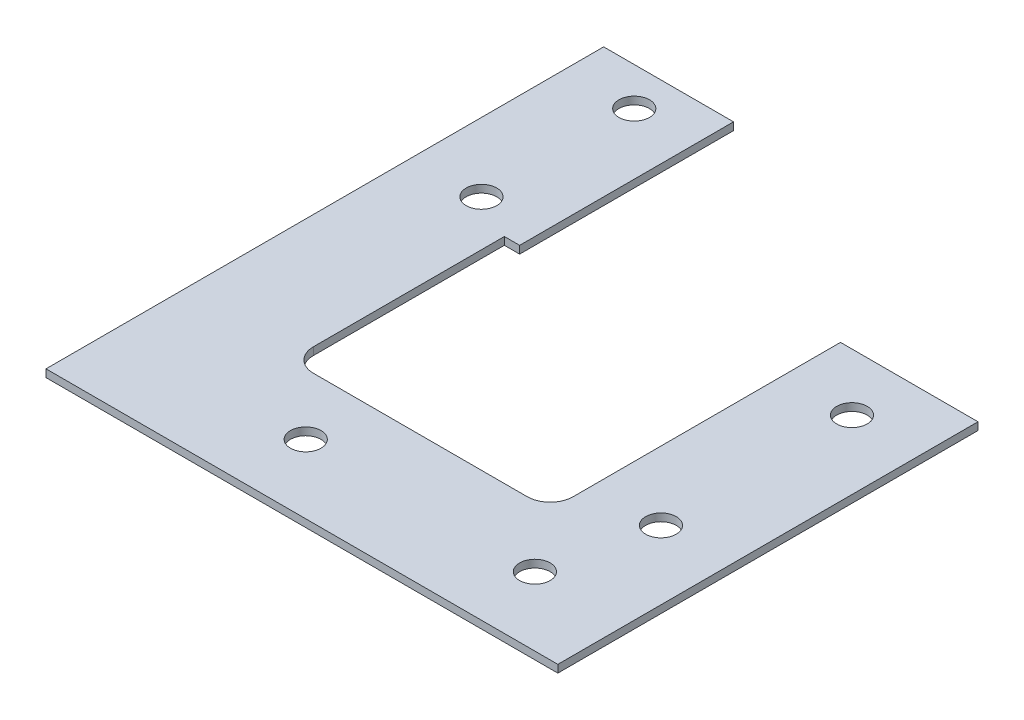
from build123d import *

# Parameters (mm, degrees)
SKETCH1_R           = 2
BOSS_EXTRUDE2_DEPTH = 1


with BuildPart() as part:
    # Sketch1 → Boss-Extrude2 (new body)
    with BuildSketch(Plane(origin=(0, 0, 0), x_dir=(1, 0, 0), z_dir=(0, 1, 0))):
        with BuildLine():
            Line((0, 40), (15, 40))
            Line((15, 40), (15, 0))
            Line((15, 0), (15, -15))
            Line((15, -15), (-52, -15))
            Line((-52, -15), (-52, 58))
            Line((-52, 58), (-37, 58))
            Line((-37, 58), (-35, 58))
            Line((-35, 58), (-35, 30))
            Line((-35, 30), (-37, 30))
            Line((-37, 30), (-37, 5))
            ThreePointArc((-37, 5), (-36.121320344, 2.878679656), (-34, 2))
            Line((-34, 2), (-6, 2))
            ThreePointArc((-6, 2), (-3.878679656, 2.878679656), (-3, 5))
            Line((-3, 5), (-3, 40))
            Line((-3, 40), (0, 40))
        make_face()
        with Locations((6, 32.5)):
            Circle(SKETCH1_R, mode=Mode.SUBTRACT)
        with Locations((6, 7.5)):
            Circle(SKETCH1_R, mode=Mode.SUBTRACT)
        with Locations((-43, 53)):
            Circle(SKETCH1_R, mode=Mode.SUBTRACT)
        with Locations((-43, 33)):
            Circle(SKETCH1_R, mode=Mode.SUBTRACT)
        with Locations((-27, -6)):
            Circle(SKETCH1_R, mode=Mode.SUBTRACT)
        with Locations((3, -6)):
            Circle(SKETCH1_R, mode=Mode.SUBTRACT)
    extrude(amount=BOSS_EXTRUDE2_DEPTH)


solid = part.part
